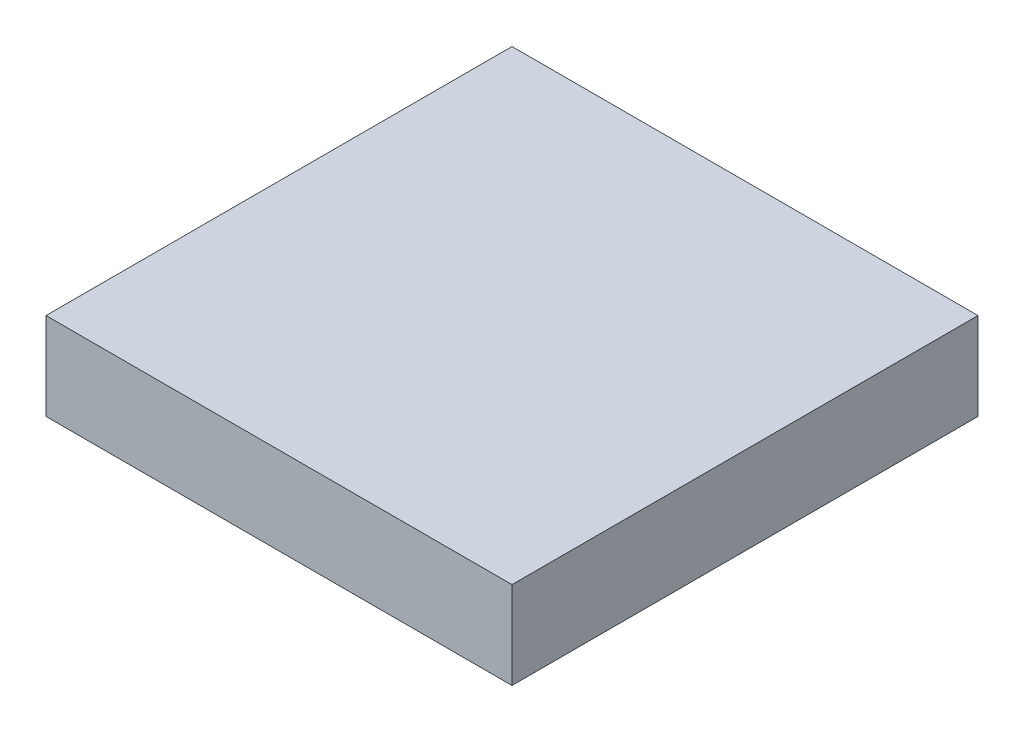
from build123d import *

# Parameters (mm, degrees)
SKETCH1_W           = 16
SKETCH1_H           = 16
BOSS_EXTRUDE1_DEPTH = 3
SKETCH2_W           = 12
SKETCH2_H           = 12
SKETCH2_R           = 2.5
CUT_EXTRUDE1_DEPTH  = 2
SKETCH3_R           = 0.75
CUT_EXTRUDE2_DEPTH  = 2


with BuildPart() as part:
    # Sketch1 → Boss-Extrude1 (new body)
    with BuildSketch(Plane(origin=(0, 0, 0), x_dir=(1, 0, 0), z_dir=(0, 1, 0))):
        Rectangle(SKETCH1_W, SKETCH1_H)
    extrude(amount=BOSS_EXTRUDE1_DEPTH)

    # Sketch2 → Cut-Extrude1 (cut)
    with BuildSketch(Plane.XZ):
        Rectangle(SKETCH2_W, SKETCH2_H)
        Circle(SKETCH2_R, mode=Mode.SUBTRACT)
    extrude(amount=-CUT_EXTRUDE1_DEPTH, mode=Mode.SUBTRACT)

    # Sketch3 → Cut-Extrude2 (cut)
    with BuildSketch(Plane.XZ):
        with Locations((-7, 7)):
            Circle(SKETCH3_R)
        with Locations((7, 7)):
            Circle(SKETCH3_R)
        with Locations((7, -7)):
            Circle(SKETCH3_R)
        with Locations((-7, -7)):
            Circle(SKETCH3_R)
    extrude(amount=-CUT_EXTRUDE2_DEPTH, mode=Mode.SUBTRACT)


solid = part.part
